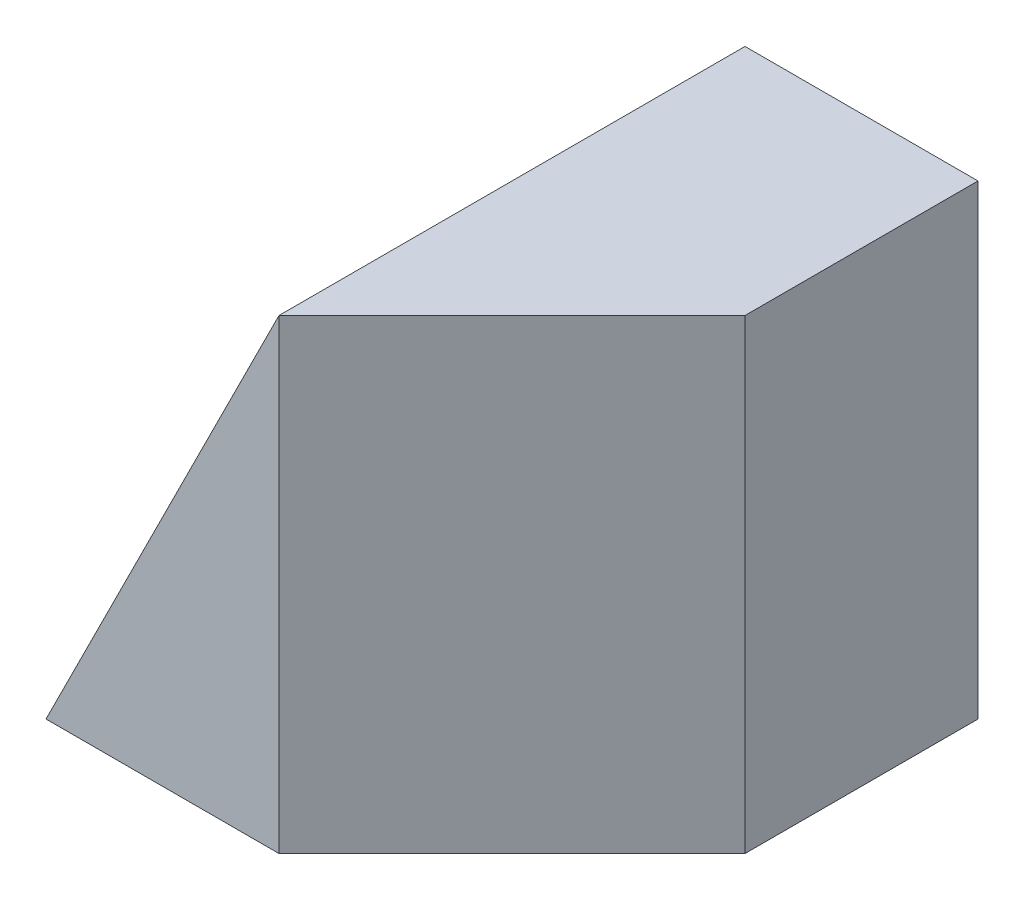
from build123d import *

# Parameters (mm, degrees)
SKETCH1_W           = 40
SKETCH1_H           = 40
BOSS_EXTRUDE1_DEPTH = 40
CUT_EXTRUDE1_DEPTH  = 40
CUT_EXTRUDE2_DEPTH  = 40


with BuildPart() as part:
    # Sketch1 → Boss-Extrude1 (new body)
    with BuildSketch(Plane.XY):
        with Locations((20, 20)):
            Rectangle(SKETCH1_W, SKETCH1_H)
    extrude(amount=BOSS_EXTRUDE1_DEPTH)

    # Sketch2 → Cut-Extrude1 (cut)
    with BuildSketch(Plane.XY.offset(40)):
        Polygon((0, 0), (20, 40), (0, 40), align=None)
    extrude(amount=-CUT_EXTRUDE1_DEPTH, mode=Mode.SUBTRACT)

    # Sketch3 → Cut-Extrude2 (cut)
    with BuildSketch(Plane(origin=(0, 40, 0), x_dir=(1, 0, 0), z_dir=(0, 1, 0))):
        Polygon((20, -40), (40, -20), (40, -40), align=None)
    extrude(amount=-CUT_EXTRUDE2_DEPTH, mode=Mode.SUBTRACT)


solid = part.part
